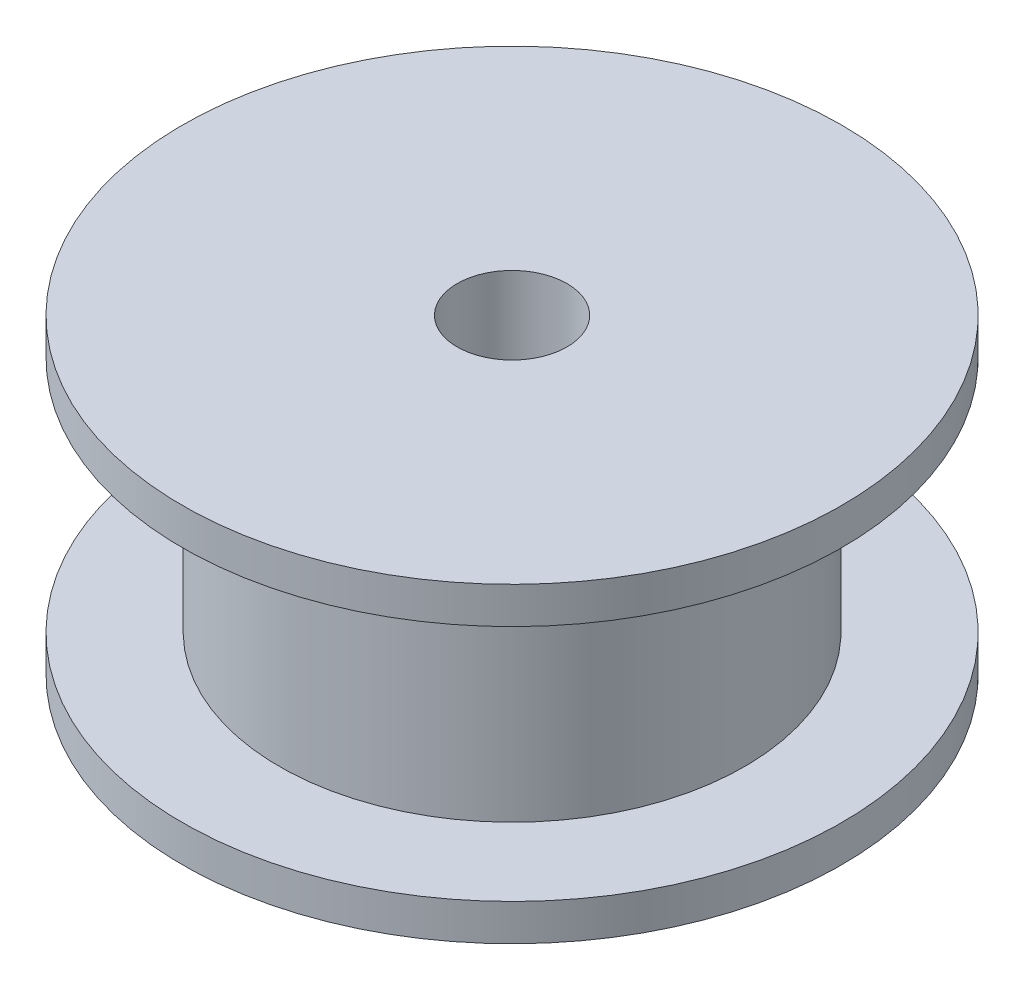
from build123d import *


with BuildPart() as part:
    # Esboço1 → Revolução1 (revolve)
    with BuildSketch(Plane.XY):
        Polygon((1.5, 0), (9, 0), (9, 1), (6.35, 1), (6.35, 7.5), (9, 7.5), (9, 8.5), (1.5, 8.5), align=None)
    revolve(axis=Axis((0, 0, 0), (0, 1, 0)))


solid = part.part
